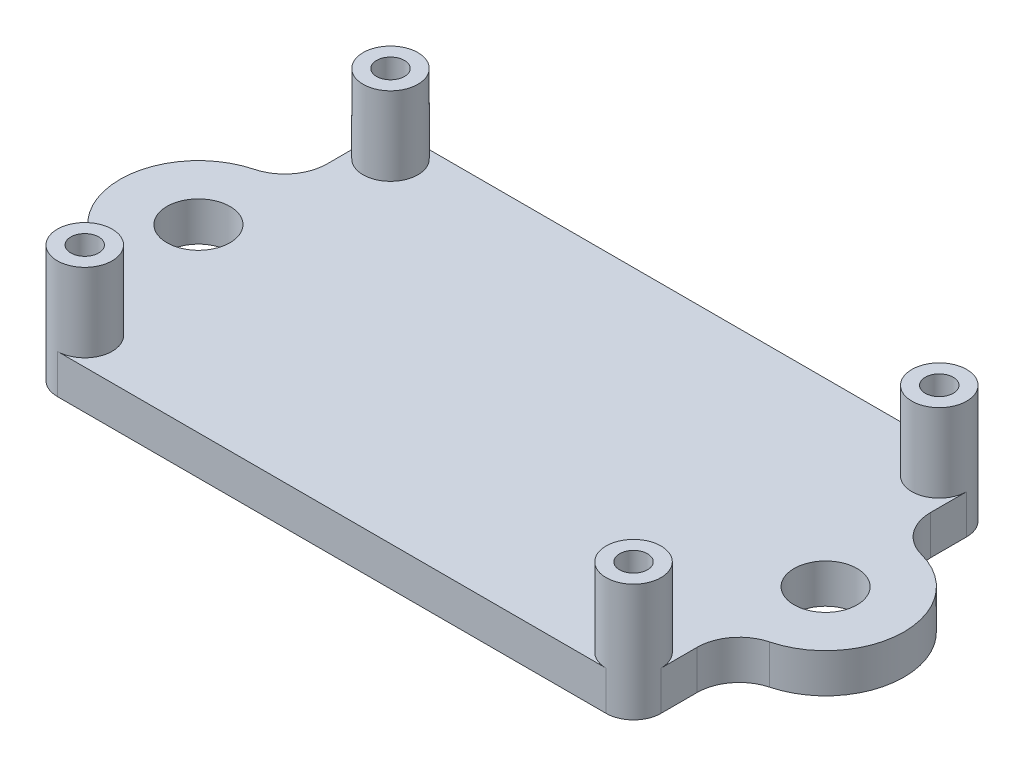
from build123d import *

# Parameters (mm, degrees)
BOSS_EXTRUDE1_DEPTH    = 3.175
FILLET1_R              = 3.429
F_10_CLEARANCE_HOLE1_D = 5.1054
SKETCH4_R              = 2.2225
BOSS_EXTRUDE2_DEPTH    = 6.35
F_4_40_TAPPED_HOLE1_D  = 2.2606
CUT_EXTRUDE1_DEPTH     = 4.175
MIRROR2_COPY_1_DEPTH   = 4.175


with BuildPart() as part:
    # Sketch1 → Boss-Extrude1 (new body)
    with BuildSketch(Plane(origin=(0, 0, 0), x_dir=(1, 0, 0), z_dir=(0, 1, 0))):
        with BuildLine():
            Line((-24.4475, 14.605), (24.4475, 14.605))
            Line((24.4475, 14.605), (24.4475, 6.278156079))
            ThreePointArc((24.4475, 6.278156079), (31.75, 0), (24.4475, -6.278156079))
            Line((24.4475, -6.278156079), (24.4475, -14.605))
            Line((24.4475, -14.605), (-24.4475, -14.605))
            Line((-24.4475, -14.605), (-24.4475, -6.278156079))
            ThreePointArc((-24.4475, -6.278156079), (-31.75, 0), (-24.4475, 6.278156079))
            Line((-24.4475, 6.278156079), (-24.4475, 14.605))
        make_face()
    extrude(amount=BOSS_EXTRUDE1_DEPTH)

    # Fillet1
    fillet1_edges = [part.edges().sort_by_distance(p)[0] for p in [
        (-24.4475, 1.5875, 6.278156079),
        (-24.4475, 1.5875, -6.278156079),
        (24.4475, 1.5875, -6.278156079),
        (24.4475, 1.5875, 6.278156079),
    ]]
    fillet(fillet1_edges, radius=FILLET1_R)

    # #10 Clearance Hole1 (through all)
    with Locations(Plane(origin=(0, 3.175, 0), x_dir=(1, 0, 0), z_dir=(0, 1, 0))):
        with Locations((25.4, 0), (-25.4, 0)):
            Hole(F_10_CLEARANCE_HOLE1_D / 2)

    # Sketch4 → Boss-Extrude2 (add)
    with BuildSketch(Plane(origin=(0, 3.175, 0), x_dir=(1, 0, 0), z_dir=(0, 1, 0))):
        with Locations((-22.225, 12.3825)):
            Circle(SKETCH4_R)
        with Locations((22.225, 12.3825)):
            Circle(SKETCH4_R)
        with Locations((22.225, -12.3825)):
            Circle(SKETCH4_R)
        with Locations((-22.225, -12.3825)):
            Circle(SKETCH4_R)
    extrude(amount=BOSS_EXTRUDE2_DEPTH)

    # #4-40 Tapped Hole1 (through all)
    with Locations(Plane(origin=(0, 9.525, 0), x_dir=(1, 0, 0), z_dir=(0, 1, 0))):
        with Locations((22.225, 12.3825), (-22.225, 12.3825), (-22.225, -12.3825), (22.225, -12.3825)):
            Hole(F_4_40_TAPPED_HOLE1_D / 2)

    # Sketch7 → Cut-Extrude1 (cut, through all)
    with BuildSketch(Plane(origin=(0, 3.175, 0), x_dir=(1, 0, 0), z_dir=(0, 1, 0))):
        with BuildLine():
            Line((-24.4475, -14.605), (-22.225, -14.605))
            ThreePointArc((-22.225, -14.605), (-23.796544821, -13.954044821), (-24.4475, -12.3825))
            Line((-24.4475, -12.3825), (-24.4475, -14.605))
        make_face()
    cut_extrude1 = extrude(amount=-CUT_EXTRUDE1_DEPTH, mode=Mode.SUBTRACT)

    # Mirror1: Cut-Extrude1 across plane
    add(cut_extrude1.mirror(Plane.XY), mode=Mode.SUBTRACT)

    # Mirror2: Cut-Extrude1 across plane
    add(cut_extrude1.mirror(Plane(origin=(0, 0, 0), x_dir=(0, 0, 1), z_dir=(1, 0, 0))), mode=Mode.SUBTRACT)

    # Mirror2 copy 1 sketch → Mirror2 copy 1 (cut, through all)
    with BuildSketch(Plane(origin=(0, 3.175, 0), x_dir=(-1, 0, 0), z_dir=(0, 1, 0))):
        with BuildLine():
            Line((-24.4475, -14.605), (-22.225, -14.605))
            ThreePointArc((-22.225, -14.605), (-23.796544821, -13.954044821), (-24.4475, -12.3825))
            Line((-24.4475, -12.3825), (-24.4475, -14.605))
        make_face()
    extrude(amount=-MIRROR2_COPY_1_DEPTH, mode=Mode.SUBTRACT)


solid = part.part
